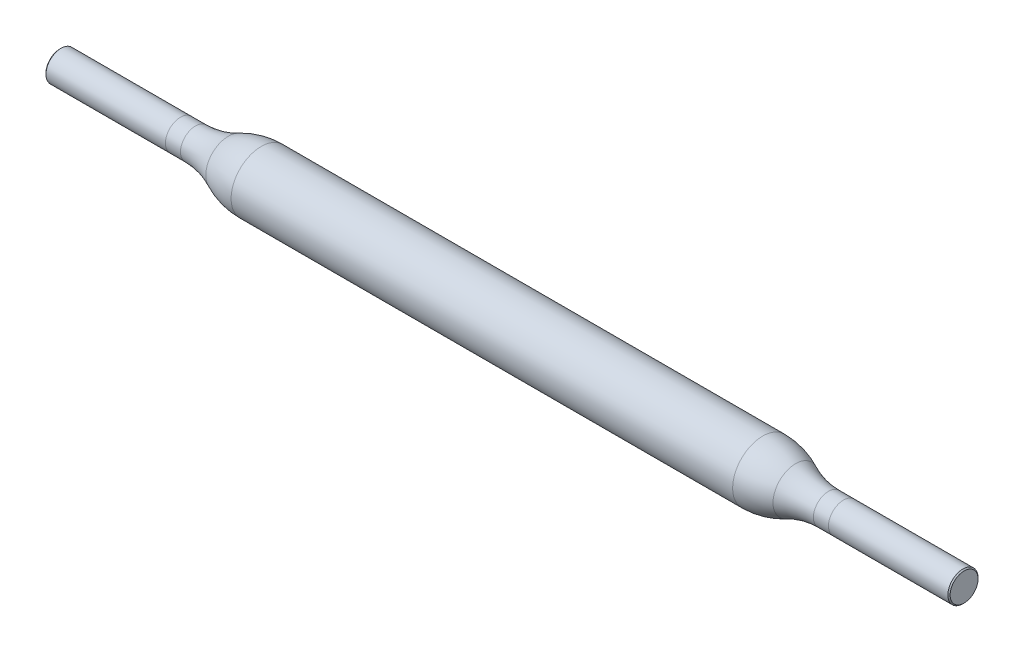
from build123d import *

# Parameters (mm, degrees)
CHAMFER1_SIZE = 0.075


with BuildPart() as part:
    # Sketch1 → Revolve1 (revolve)
    with BuildSketch(Plane.XY):
        with BuildLine():
            Line((-30, 0), (30, 0))
            Line((30, 0), (30, 1))
            Line((30, 1), (21, 1))
            ThreePointArc((21, 1), (19.881966011, 1.126602828), (18.820550528, 1.5))
            ThreePointArc((18.820550528, 1.5), (17.759135045, 1.873397172), (16.641101056, 2))
            Line((16.641101056, 2), (-16.641101056, 2))
            ThreePointArc((-16.641101056, 2), (-17.759135045, 1.873397172), (-18.820550528, 1.5))
            ThreePointArc((-18.820550528, 1.5), (-19.881966011, 1.126602828), (-21, 1))
            Line((-21, 1), (-30, 1))
            Line((-30, 1), (-30, 0))
        make_face()
    revolve(axis=Axis((-30, 0, 0), (1, 0, 0)))

    # Chamfer1
    chamfer1_edges = [part.edges().sort_by_distance(p)[0] for p in [
        (-30, -1, 0),
        (30, -1, 0),
    ]]
    chamfer(chamfer1_edges, length=CHAMFER1_SIZE)


solid = part.part
